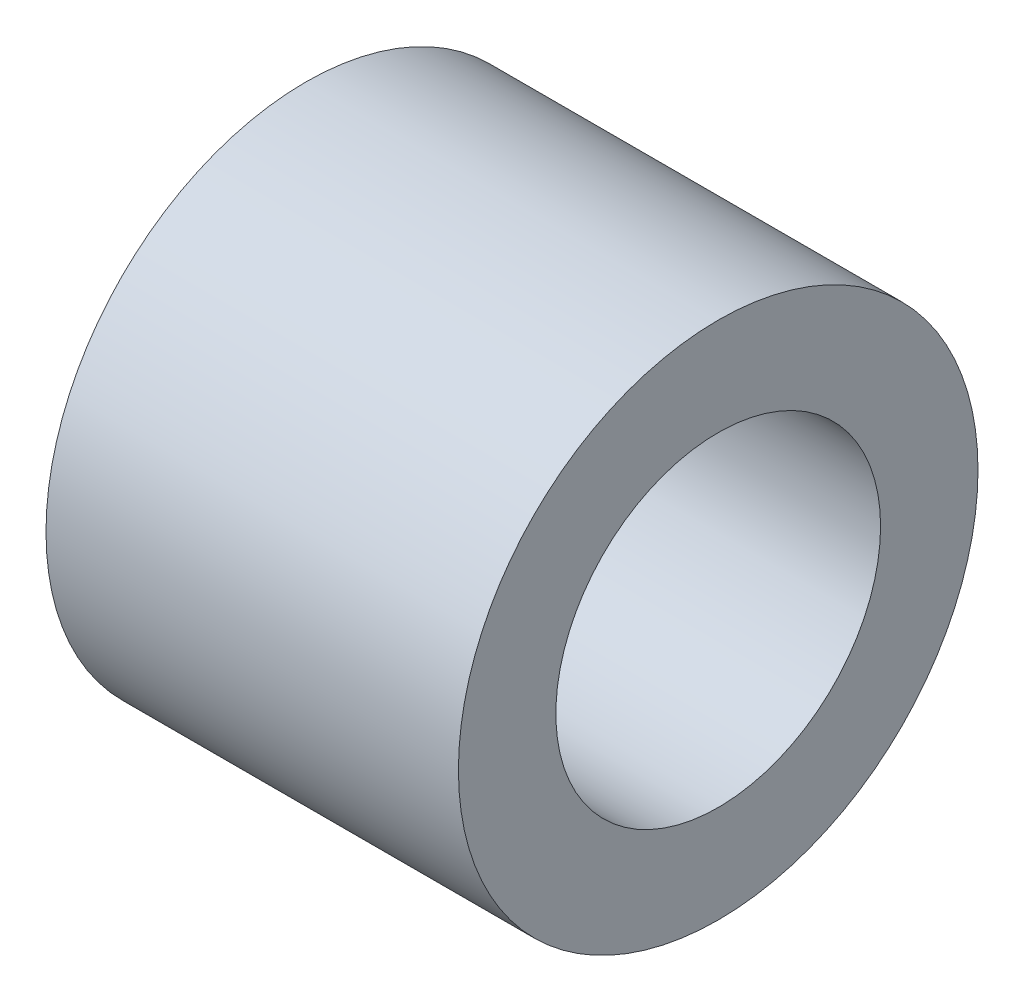
from build123d import *

# Parameters (mm, degrees)
SKETCH1_W = 6.35
SKETCH1_H = 1.5


with BuildPart() as part:
    # Sketch1 → Revolve1 (revolve)
    with BuildSketch(Plane.XY):
        with Locations((0, 3.25)):
            Rectangle(SKETCH1_W, SKETCH1_H)
    revolve(axis=Axis((0, 0, 0), (-1, 0, 0)))


solid = part.part
